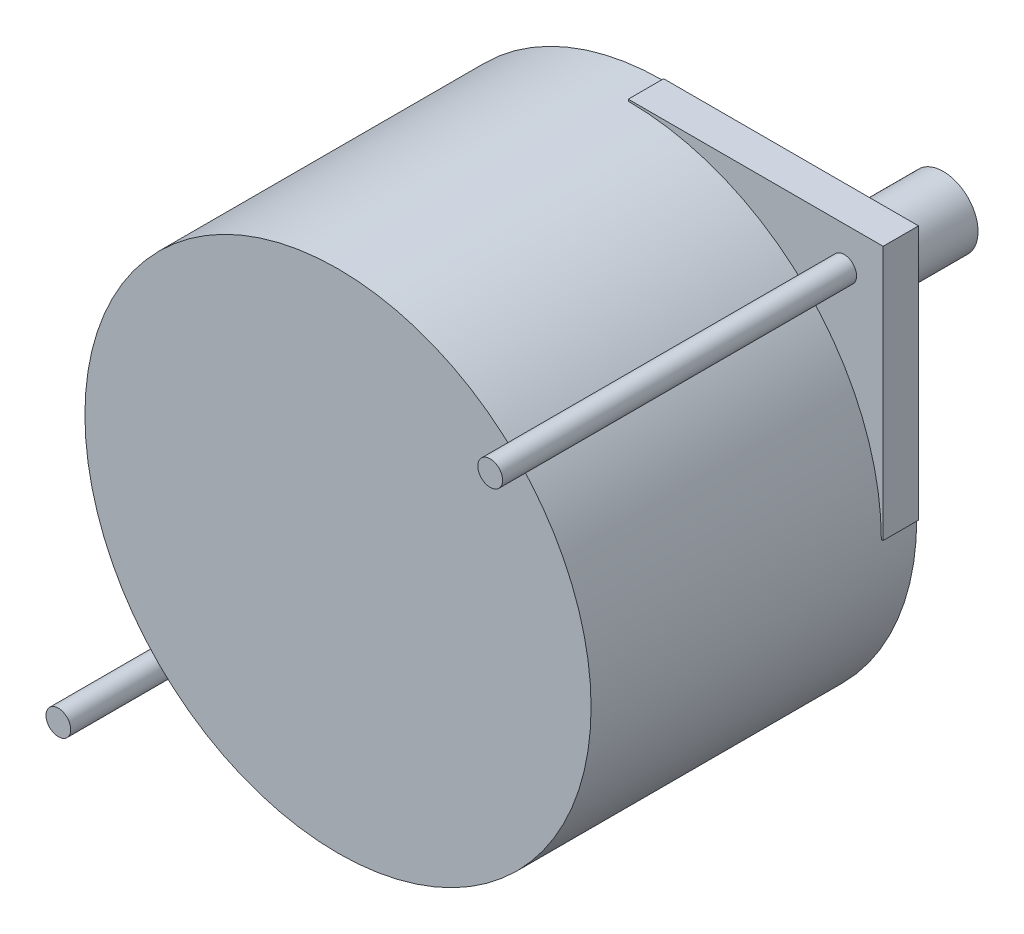
from build123d import *

# Parameters (mm, degrees)
SKETCH1_W           = 36.576
SKETCH1_H           = 36.576
BOSS_EXTRUDE1_DEPTH = 2.54
SKETCH2_R           = 0.889
BOSS_EXTRUDE2_DEPTH = 25.4
CUT_EXTRUDE4_DEPTH  = 3.54
SKETCH4_R           = 8.001
BOSS_EXTRUDE3_DEPTH = 1.016
SKETCH5_R           = 2.49555
BOSS_EXTRUDE4_DEPTH = 19.05
SKETCH6_R           = 18.161
BOSS_EXTRUDE5_DEPTH = 20.828


with BuildPart() as part:
    # Sketch1 → Boss-Extrude1 (new body)
    with BuildSketch(Plane.XY):
        with Locations((17.649916168, -17.343808383)):
            Rectangle(SKETCH1_W, SKETCH1_H)
    extrude(amount=BOSS_EXTRUDE1_DEPTH)

    # Sketch2 → Boss-Extrude2 (add)
    with BuildSketch(Plane.XY.offset(2.54)):
        with Locations((33.143916168, -1.849808383)):
            Circle(SKETCH2_R)
        with Locations((2.155916168, -32.837808383)):
            Circle(SKETCH2_R)
    extrude(amount=BOSS_EXTRUDE2_DEPTH)

    # Sketch3 → Cut-Extrude4 (cut, through all)
    with BuildSketch(Plane.XY.offset(2.54)):
        with BuildLine():
            Line((-0.638083832, 0.944191617), (-0.638083832, -17.343808383))
            Line((-0.638083832, -17.343808383), (-0.511083832, -17.343808383))
            ThreePointArc((-0.511083832, -17.343808383), (4.808149915, -4.50204213), (17.649916168, 0.817191617))
            Line((17.649916168, 0.817191617), (17.649916168, 0.944191617))
            Line((17.649916168, 0.944191617), (-0.638083832, 0.944191617))
        make_face()
        with BuildLine():
            Line((35.937916168, -35.631808383), (17.649916168, -35.631808383))
            Line((17.649916168, -35.631808383), (17.649916168, -35.504808383))
            ThreePointArc((17.649916168, -35.504808383), (30.491682421, -30.185574636), (35.810916168, -17.343808383))
            Line((35.810916168, -17.343808383), (35.937916168, -17.343808383))
            Line((35.937916168, -17.343808383), (35.937916168, -35.631808383))
        make_face()
    extrude(amount=-CUT_EXTRUDE4_DEPTH, mode=Mode.SUBTRACT)

    # Sketch4 → Boss-Extrude3 (add)
    with BuildSketch(Plane(origin=(0, 0, 0), x_dir=(-1, 0, 0), z_dir=(0, 0, -1))):
        with Locations((-17.649916168, -17.343808383)):
            Circle(SKETCH4_R)
    extrude(amount=BOSS_EXTRUDE3_DEPTH)

    # Sketch5 → Boss-Extrude4 (add)
    with BuildSketch(Plane(origin=(0, 0, -1.016), x_dir=(-1, 0, 0), z_dir=(0, 0, -1))):
        with Locations((-17.649916168, -17.343808383)):
            Circle(SKETCH5_R)
    extrude(amount=BOSS_EXTRUDE4_DEPTH)

    # Sketch6 → Boss-Extrude5 (add)
    with BuildSketch(Plane.XY.offset(2.54)):
        with Locations((17.649916168, -17.343808383)):
            Circle(SKETCH6_R)
    extrude(amount=BOSS_EXTRUDE5_DEPTH)


solid = part.part
